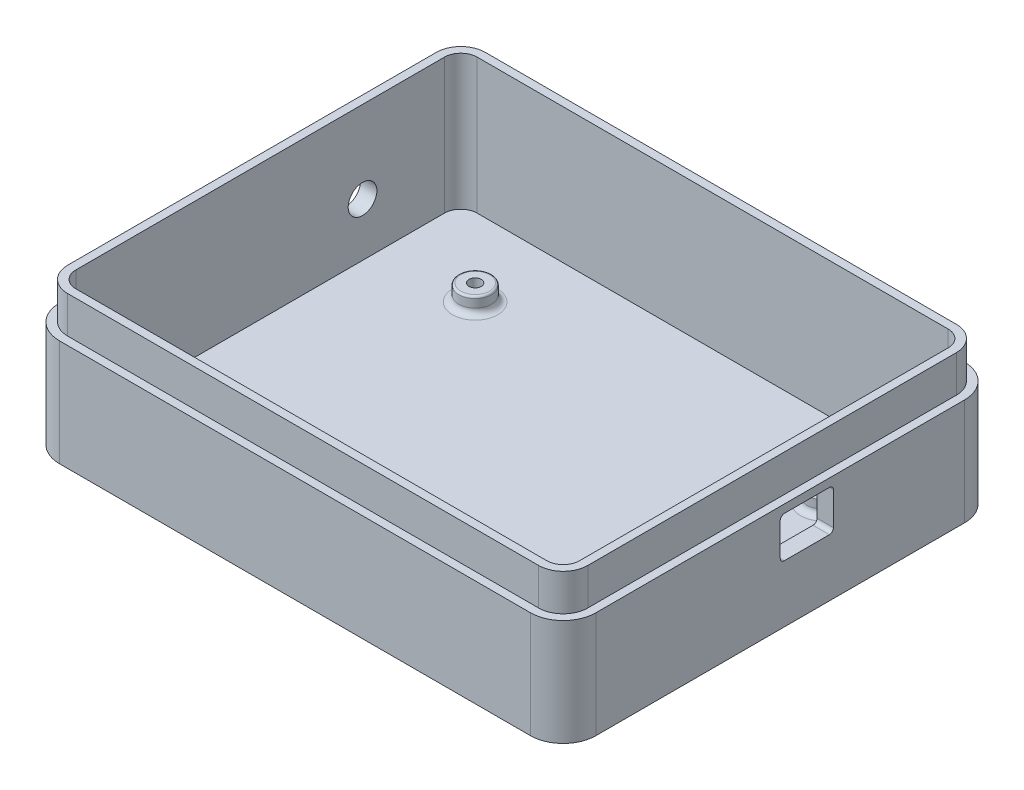
from build123d import *

# Parameters (mm, degrees)
CROQUIS1_W              = 131
CROQUIS1_H              = 106
CROQUIS1_R              = 1.5
SALIENTE_EXTRUIR1_DEPTH = 26
REDONDEO2_R             = 8
VACIADO1_T              = -2
CROQUIS3_R              = 4
CROQUIS3_R_2            = 1.5
SALIENTE_EXTRUIR2_DEPTH = 4
REDONDEO4_R             = 1.5
REDONDEO5_R             = 0.5
SALIENTE_EXTRUIR3_DEPTH = 33
CORTAR_EXTRUIR2_REACH   = 133
CORTAR_EXTRUIR3_REACH   = 133
CROQUIS7_R              = 3.5


with BuildPart() as part:
    # Croquis1 → Saliente-Extruir1 (new body)
    with BuildSketch(Plane(origin=(0, 0, 0), x_dir=(1, 0, 0), z_dir=(0, 1, 0))):
        Rectangle(CROQUIS1_W, CROQUIS1_H)
        with Locations((42.5, 30)):
            Circle(CROQUIS1_R, mode=Mode.SUBTRACT)
        with Locations((42.5, -30)):
            Circle(CROQUIS1_R, mode=Mode.SUBTRACT)
        with Locations((-42.5, 30)):
            Circle(CROQUIS1_R, mode=Mode.SUBTRACT)
        with Locations((-42.5, -30)):
            Circle(CROQUIS1_R, mode=Mode.SUBTRACT)
        with Locations((-42.5, -30)):
            Circle(CROQUIS1_R)
        with Locations((-42.5, 30)):
            Circle(CROQUIS1_R)
        with Locations((42.5, 30)):
            Circle(CROQUIS1_R)
        with Locations((42.5, -30)):
            Circle(CROQUIS1_R)
    extrude(amount=SALIENTE_EXTRUIR1_DEPTH)

    # Redondeo2
    redondeo2_edges = [part.edges().sort_by_distance(p)[0] for p in [
        (-65.5, 13, -53),
        (65.5, 13, -53),
        (65.5, 13, 53),
        (-65.5, 13, 53),
    ]]
    fillet(redondeo2_edges, radius=REDONDEO2_R)

    # Vaciado1
    vaciado1_openings = [part.faces().sort_by_distance(p)[0] for p in [
        (0, 26, 0),
    ]]
    offset(amount=VACIADO1_T, openings=vaciado1_openings, kind=Kind.INTERSECTION)

    # Croquis3 → Saliente-Extruir2 (add)
    with BuildSketch(Plane(origin=(0, 2, 0), x_dir=(1, 0, 0), z_dir=(0, 1, 0))):
        with Locations((46, 30)):
            Circle(CROQUIS3_R)
        with Locations((46, 30)):
            Circle(CROQUIS3_R_2, mode=Mode.SUBTRACT)
        with Locations((-39, 30)):
            Circle(CROQUIS3_R)
        with Locations((-39, 30)):
            Circle(CROQUIS3_R_2, mode=Mode.SUBTRACT)
        with Locations((46, -30)):
            Circle(CROQUIS3_R)
        with Locations((46, -30)):
            Circle(CROQUIS3_R_2, mode=Mode.SUBTRACT)
        with Locations((-39, -30)):
            Circle(CROQUIS3_R)
        with Locations((-39, -30)):
            Circle(CROQUIS3_R_2, mode=Mode.SUBTRACT)
    extrude(amount=SALIENTE_EXTRUIR2_DEPTH)

    # Redondeo4
    redondeo4_edges = [part.edges().sort_by_distance(p)[0] for p in [
        (42, 2, -30),
        (42, 2, 30),
        (-43, 2, 30),
        (-43, 2, -30),
    ]]
    fillet(redondeo4_edges, radius=REDONDEO4_R)

    # Redondeo5
    redondeo5_edges = [part.edges().sort_by_distance(p)[0] for p in [
        (42, 6, -30),
        (42, 6, 30),
        (-43, 6, 30),
        (-43, 6, -30),
    ]]
    fillet(redondeo5_edges, radius=REDONDEO5_R)

    # Croquis4 → Saliente-Extruir3 (add)
    with BuildSketch(Plane(origin=(0, 2, 0), x_dir=(1, 0, 0), z_dir=(0, 1, 0))):
        with BuildLine():
            ThreePointArc((63.5, 45), (61.742640687, 49.242640687), (57.5, 51))
            Line((57.5, 51), (-57.5, 51))
            ThreePointArc((-57.5, 51), (-61.742640687, 49.242640687), (-63.5, 45))
            Line((-63.5, 45), (-63.5, -45))
            ThreePointArc((-63.5, -45), (-61.742640687, -49.242640687), (-57.5, -51))
            Line((-57.5, -51), (57.5, -51))
            ThreePointArc((57.5, -51), (61.742640687, -49.242640687), (63.5, -45))
            Line((63.5, -45), (63.5, 45))
        make_face()
        with BuildLine():
            ThreePointArc((-57.5, 49), (-60.328427125, 47.828427125), (-61.5, 45))
            Line((-61.5, 45), (-61.5, -45))
            ThreePointArc((-61.5, -45), (-60.328427125, -47.828427125), (-57.5, -49))
            Line((-57.5, -49), (57.5, -49))
            ThreePointArc((57.5, -49), (60.328427125, -47.828427125), (61.5, -45))
            Line((61.5, -45), (61.5, 45))
            ThreePointArc((61.5, 45), (60.328427125, 47.828427125), (57.5, 49))
            Line((57.5, 49), (-57.5, 49))
        make_face(mode=Mode.SUBTRACT)
    extrude(amount=SALIENTE_EXTRUIR3_DEPTH)

    # Croquis5 → Cortar-Extruir2 (cut, up to next)
    with BuildSketch(Plane(origin=(65.5, 0, 0), x_dir=(0, 0, -1), z_dir=(1, 0, 0)), mode=Mode.PRIVATE) as cortar_extruir2_sk1:
        with BuildLine():
            Line((1, 24), (12, 24))
            ThreePointArc((12, 24), (12.707106781, 23.707106781), (13, 23))
            Line((13, 23), (13, 15))
            ThreePointArc((13, 15), (12.707106781, 14.292893219), (12, 14))
            Line((12, 14), (1, 14))
            ThreePointArc((1, 14), (0.292893219, 14.292893219), (0, 15))
            Line((0, 15), (0, 23))
            ThreePointArc((0, 23), (0.292893219, 23.707106781), (1, 24))
        make_face()
    cortar_extruir2_tool1 = extrude(cortar_extruir2_sk1.sketch, amount=-CORTAR_EXTRUIR2_REACH, mode=Mode.PRIVATE) & part.part
    add(cortar_extruir2_tool1.solids().sort_by_distance((65.5, 19, -6.5))[0], mode=Mode.SUBTRACT)

    # Croquis7 → Cortar-Extruir3 (cut, up to next)
    with BuildSketch(Plane.ZY.offset(65.5), mode=Mode.PRIVATE) as cortar_extruir3_sk1:
        with Locations((-25, 15)):
            Circle(CROQUIS7_R)
    cortar_extruir3_tool1 = extrude(cortar_extruir3_sk1.sketch, amount=-CORTAR_EXTRUIR3_REACH, mode=Mode.PRIVATE) & part.part
    add(cortar_extruir3_tool1.solids().sort_by_distance((-65.5, 15, -25))[0], mode=Mode.SUBTRACT)


solid = part.part
